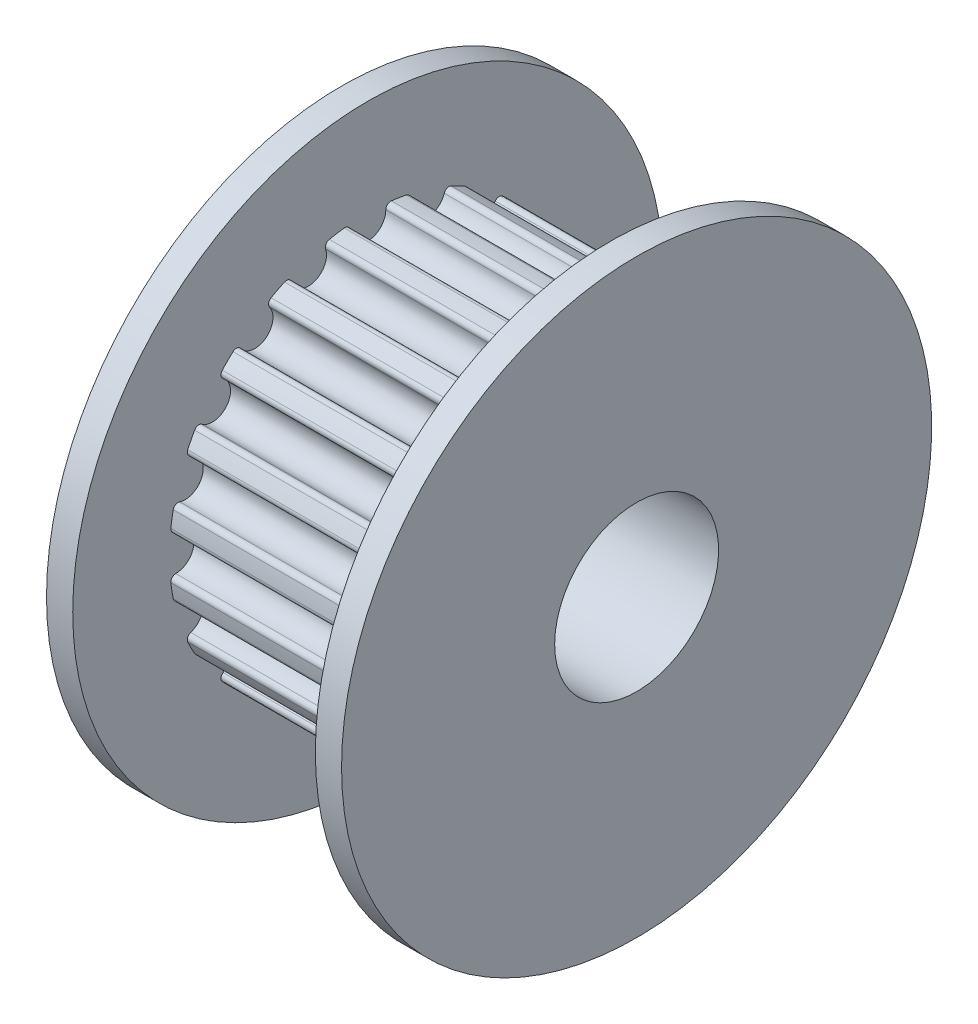
from build123d import *

# Parameters (mm, degrees)
SKETCH_3_R               = 0.55
F_20TOOTH_DEPTH          = 7.4
FILLET_1_R               = 0.15
SCHIZZO1_R               = 2.5
TAGLIO_ESTRUSIONE1_DEPTH = 10


with BuildPart() as part:
    # Эскиз1 → Body (revolve)
    with BuildSketch(Plane.XY):
        Polygon((0, 9), (0, 0), (9, 0), (9, 9), (8.2, 9), (8.2, 6.05), (0.8, 6.05), (0.8, 9), align=None)
    revolve(axis=Axis((0, 0, 0), (1, 0, 0)))

    # Эскиз3 → 20tooth (cut)
    with BuildSketch(Plane(origin=(0.8, 0, 0), x_dir=(0, 0, -1), z_dir=(1, 0, 0))):
        with Locations((5.568435903, -1.809294502)):
            Circle(SKETCH_3_R)
        with Locations((4.736794502, -3.441482652)):
            Circle(SKETCH_3_R)
        with Locations((3.441482652, -4.736794502)):
            Circle(SKETCH_3_R)
        with Locations((1.809294502, -5.568435903)):
            Circle(SKETCH_3_R)
        with Locations((0, -5.855)):
            Circle(SKETCH_3_R)
        with Locations((5.855, 0)):
            Circle(SKETCH_3_R)
        with Locations((-1.809294502, -5.568435903)):
            Circle(SKETCH_3_R)
        with Locations((-3.441482652, -4.736794502)):
            Circle(SKETCH_3_R)
        with Locations((-4.736794502, -3.441482652)):
            Circle(SKETCH_3_R)
        with Locations((-5.568435903, -1.809294502)):
            Circle(SKETCH_3_R)
        with Locations((-5.855, 0)):
            Circle(SKETCH_3_R)
        with Locations((-5.568435903, 1.809294502)):
            Circle(SKETCH_3_R)
        with Locations((-4.736794502, 3.441482652)):
            Circle(SKETCH_3_R)
        with Locations((-3.441482652, 4.736794502)):
            Circle(SKETCH_3_R)
        with Locations((-1.809294502, 5.568435903)):
            Circle(SKETCH_3_R)
        with Locations((0, 5.855)):
            Circle(SKETCH_3_R)
        with Locations((1.809294502, 5.568435903)):
            Circle(SKETCH_3_R)
        with Locations((3.441482652, 4.736794502)):
            Circle(SKETCH_3_R)
        with Locations((4.736794502, 3.441482652)):
            Circle(SKETCH_3_R)
        with Locations((5.568435903, 1.809294502)):
            Circle(SKETCH_3_R)
    extrude(amount=F_20TOOTH_DEPTH, mode=Mode.SUBTRACT)

    # Скругление1
    fillet_1_edges = [part.edges().sort_by_distance(p)[0] for p in [
        (4.5, -1.365858655, 5.893804386),
        (4.5, -2.359288434, 5.571019483),
        (4.5, 0.522276943, 6.027414603),
        (4.5, -0.522276943, 6.027414603),
        (4.5, 2.359288434, 5.571019483),
        (4.5, 1.365858655, 5.893804386),
        (4.5, 3.965356335, 4.569294161),
        (4.5, 3.120294491, 5.18326753),
        (4.5, 5.18326753, 3.120294491),
        (4.5, 4.569294161, 3.965356335),
        (4.5, 5.893804386, 1.365858655),
        (4.5, 5.571019483, 2.359288434),
        (4.5, 6.027414603, -0.522276943),
        (4.5, 6.027414603, 0.522276943),
        (4.5, 5.571019483, -2.359288434),
        (4.5, 5.893804386, -1.365858655),
        (4.5, 4.569294161, -3.965356335),
        (4.5, 5.18326753, -3.120294491),
        (4.5, 3.120294491, -5.18326753),
        (4.5, 3.965356335, -4.569294161),
        (4.5, 1.365858655, -5.893804386),
        (4.5, 2.359288434, -5.571019483),
        (4.5, -1.365858655, -5.893804386),
        (4.5, -2.359288434, -5.571019483),
        (4.5, -3.965356335, -4.569294161),
        (4.5, -3.120294491, -5.18326753),
        (4.5, -5.18326753, -3.120294491),
        (4.5, -4.569294161, -3.965356335),
        (4.5, -5.893804386, -1.365858655),
        (4.5, -5.571019483, -2.359288434),
        (4.5, -6.027414603, 0.522276943),
        (4.5, -6.027414603, -0.522276943),
        (4.5, -0.522276943, -6.027414603),
        (4.5, 0.522276943, -6.027414603),
        (4.5, -5.571019483, 2.359288434),
        (4.5, -5.893804386, 1.365858655),
        (4.5, -4.569294161, 3.965356335),
        (4.5, -5.18326753, 3.120294491),
        (4.5, -3.120294491, 5.18326753),
        (4.5, -3.965356335, 4.569294161),
    ]]
    fillet(fillet_1_edges, radius=FILLET_1_R)

    # Schizzo1 → Taglio-Estrusione1 (cut, through all)
    with BuildSketch(Plane.ZY):
        Circle(SCHIZZO1_R)
    extrude(amount=-TAGLIO_ESTRUSIONE1_DEPTH, mode=Mode.SUBTRACT)


solid = part.part
